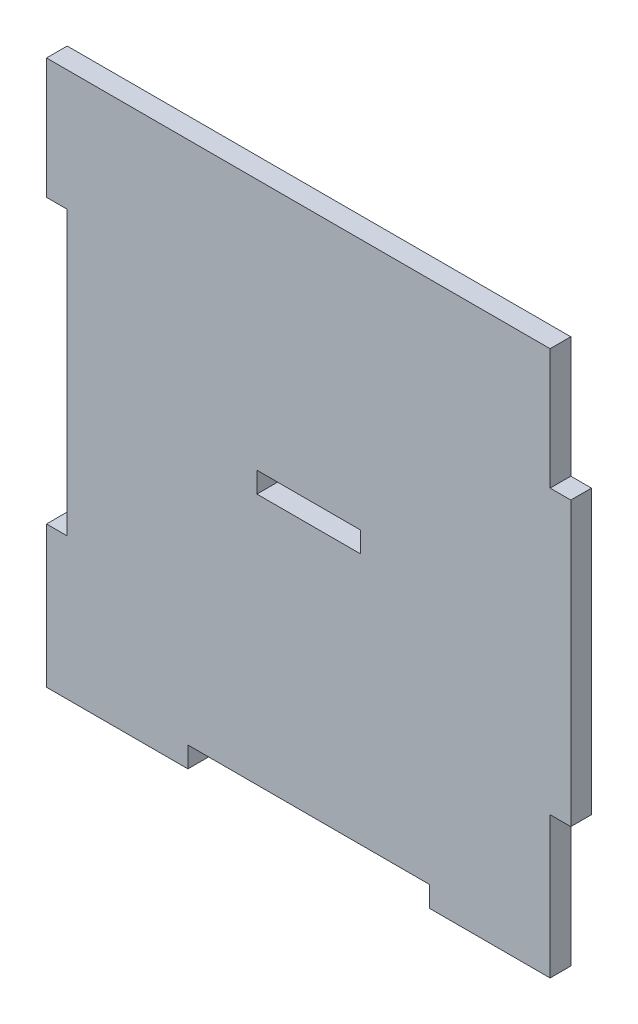
from build123d import *

# Parameters (mm, degrees)
BOSS_EXTRUDE1_DEPTH = 3
SKETCH2_W           = 15
SKETCH2_H           = 3
CUT_EXTRUDE1_DEPTH  = 3


with BuildPart() as part:
    # Sketch1 → Boss-Extrude1 (new body)
    with BuildSketch(Plane.XY):
        Polygon((-35, 38), (-17.5, 38), (17.5, 38), (35, 38), (35, 20.5), (38, 20.5), (38, -20.5), (35, -20.5), (35, -38), (35, -41), (17.5, -41), (17.5, -38), (-17.5, -38), (-17.5, -41), (-35, -41), (-38, -41), (-38, -38), (-38, -20.5), (-35, -20.5), (-35, 20.5), (-38, 20.5), (-38, 38), align=None)
    extrude(amount=BOSS_EXTRUDE1_DEPTH)

    # Sketch2 → Cut-Extrude1 (cut)
    with BuildSketch(Plane.XY.offset(3)):
        Rectangle(SKETCH2_W, SKETCH2_H)
    extrude(amount=-CUT_EXTRUDE1_DEPTH, mode=Mode.SUBTRACT)


solid = part.part
